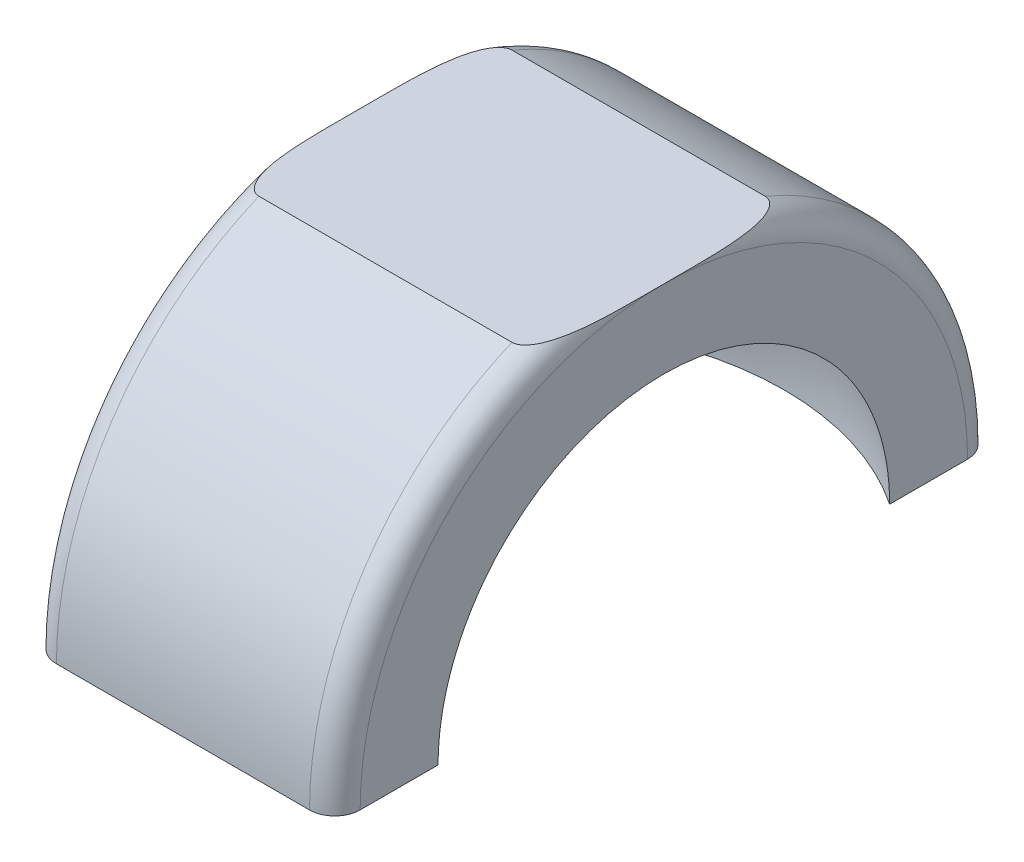
from build123d import *

# Parameters (mm, degrees)
BASE_R_VOLUTION_ANGLE   = 180
ESQUISSE2_W             = 44
ESQUISSE2_H             = 6
ENL_V_MAT_EXTRU_1_DEPTH = 25


with BuildPart() as part:
    # Esquisse1 → Base-Révolution (revolve, symmetric)
    with BuildSketch(Plane.XY) as base_r_volution_sk:
        with BuildLine():
            Line((-12, 17.839562775), (-12, 24))
            ThreePointArc((-12, 24), (-11.414213562, 25.414213562), (-10, 26))
            Line((-10, 26), (10, 26))
            ThreePointArc((10, 26), (11.414213562, 25.414213562), (12, 24))
            Line((12, 24), (12, 17.839562775))
            ThreePointArc((12, 17.839562775), (0, 21.5), (-12, 17.839562775))
        make_face()
    revolve(axis=Axis((-22, 0, 0), (1, 0, 0)), revolution_arc=BASE_R_VOLUTION_ANGLE / 2)
    revolve(base_r_volution_sk.sketch, axis=Axis((-22, 0, 0), (-1, 0, 0)), revolution_arc=BASE_R_VOLUTION_ANGLE / 2)

    # Esquisse2 → Enlèv. mat.-Extru.1 (cut, through all)
    with BuildSketch(Plane(origin=(12, 0, 0), x_dir=(0, 0, -1), z_dir=(1, 0, 0))):
        with Locations((0, 27)):
            Rectangle(ESQUISSE2_W, ESQUISSE2_H)
    extrude(amount=-ENL_V_MAT_EXTRU_1_DEPTH, mode=Mode.SUBTRACT)


solid = part.part
